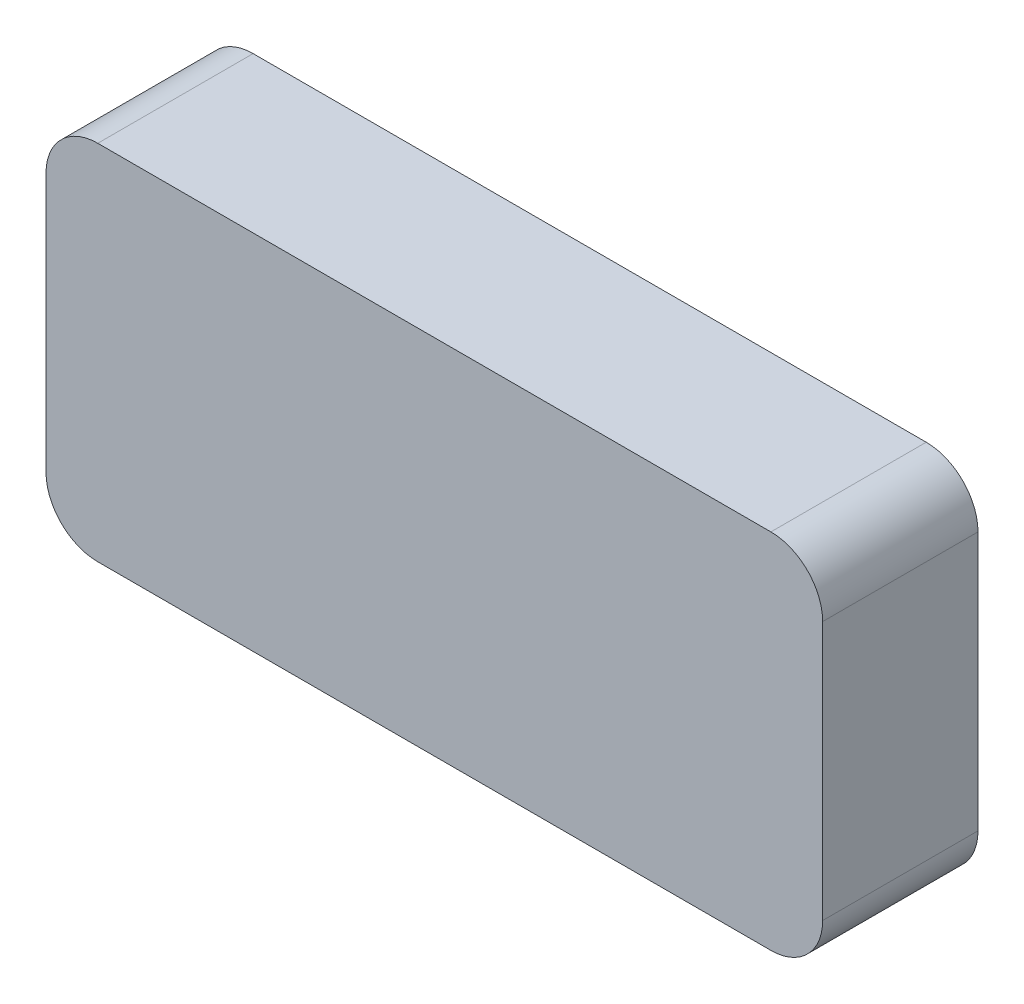
from build123d import *

# Parameters (mm, degrees)
SKETCH_1_W      = 150
SKETCH_1_H      = 70
EXTRUDE_1_DEPTH = 30
FILLET_1_R      = 10


with BuildPart() as part:
    # 스케치1 → 보스-돌출1 (new body)
    with BuildSketch(Plane.XY):
        with Locations((75, -35)):
            Rectangle(SKETCH_1_W, SKETCH_1_H)
    extrude(amount=EXTRUDE_1_DEPTH)

    # 필렛1
    fillet_1_edges = [part.edges().sort_by_distance(p)[0] for p in [
        (0, 0, 15),
        (150, 0, 15),
        (150, -70, 15),
        (0, -70, 15),
    ]]
    fillet(fillet_1_edges, radius=FILLET_1_R)


solid = part.part
